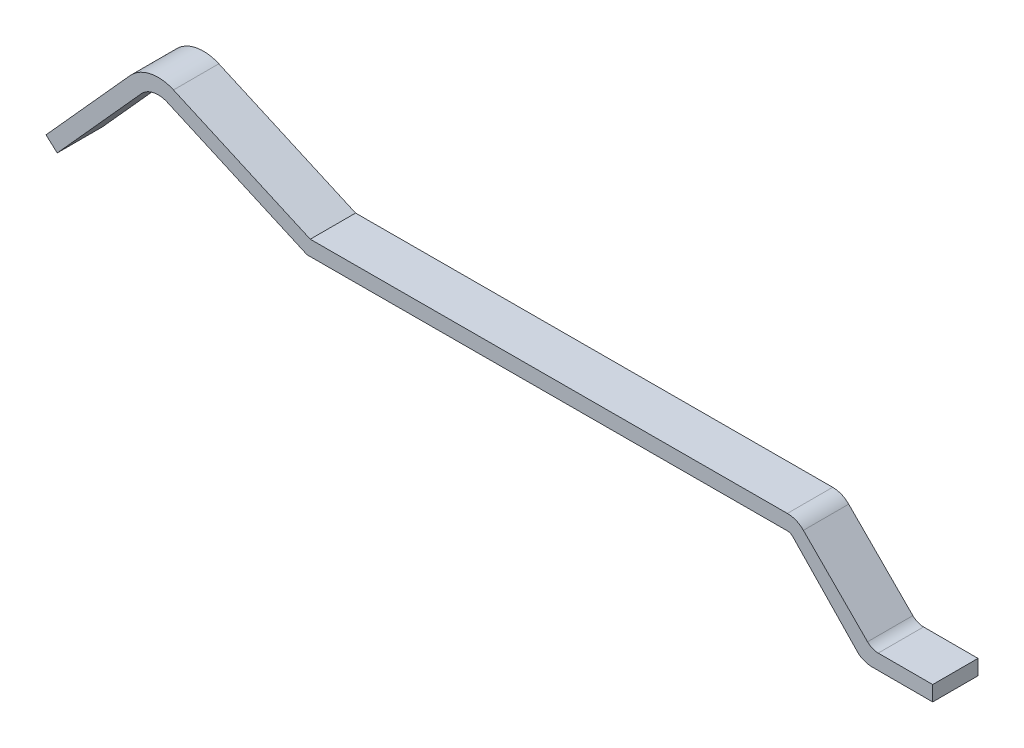
from build123d import *

# Parameters (mm, degrees)
RESSALTO_EXTRUS_O1_DEPTH = 0.3


with BuildPart() as part:
    # Esboço1 → Ressalto-extrusão1 (new body, symmetric)
    with BuildSketch(Plane.XY):
        with BuildLine():
            Line((20.691752756, 0.204274437), (20.691752756, 0.004274437))
            Line((20.691752756, 0.004274437), (19.891752756, 0.004274437))
            ThreePointArc((19.891752756, 0.004274437), (19.796884427, 0.019669447), (19.711752756, 0.064274437))
            Line((19.711752756, 0.064274437), (18.838199366, 0.975083322))
            ThreePointArc((18.838199366, 0.975083322), (18.805773821, 0.996800576), (18.767488688, 1.004370491))
            Line((18.767488688, 1.004370491), (12.407488688, 0.99))
            Line((12.407488688, 0.99), (10.557971552, 1.813458083))
            ThreePointArc((10.557971552, 1.813458083), (10.373577052, 1.832838725), (10.213007112, 1.740133627))
            Line((10.213007112, 1.740133627), (9.099531826, 0.503494039))
            Line((9.099531826, 0.503494039), (8.95090286, 0.637320161))
            Line((8.95090286, 0.637320161), (10.064378147, 1.873959748))
            ThreePointArc((10.064378147, 1.873959748), (10.331994714, 2.028468246), (10.639318881, 1.996167174))
            Line((10.639318881, 1.996167174), (12.45, 1.19))
            Line((12.45, 1.19), (18.767488688, 1.204274437))
            ThreePointArc((18.767488688, 1.204274437), (18.882345327, 1.181562894), (18.979620722, 1.116406471))
            Line((18.979620722, 1.116406471), (19.829007121, 0.263172984))
            ThreePointArc((19.829007121, 0.263172984), (19.894002269, 0.219585116), (19.970747658, 0.204274437))
            Line((19.970747658, 0.204274437), (20.691752756, 0.204274437))
        make_face()
    extrude(amount=RESSALTO_EXTRUS_O1_DEPTH, both=True)


solid = part.part
